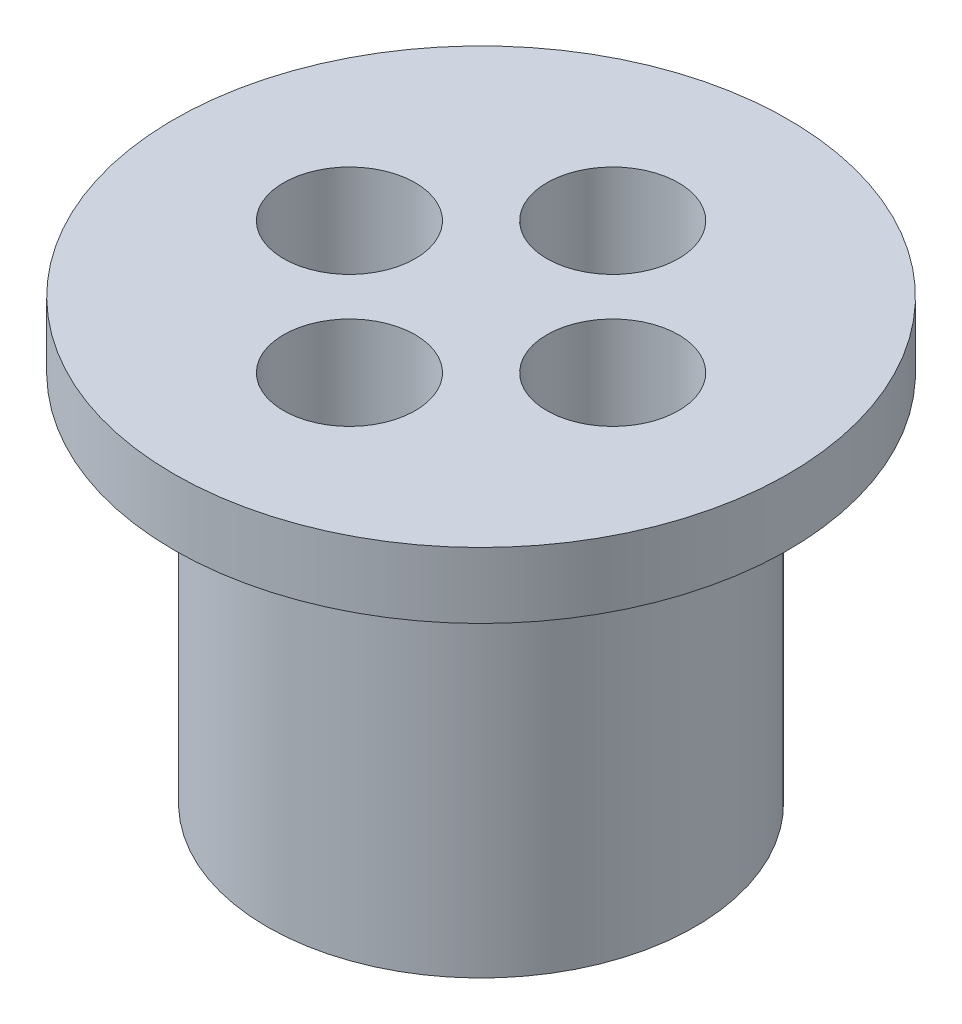
from build123d import *

# Parameters (mm, degrees)
SKETCH1_R           = 9.75
BOSS_EXTRUDE1_DEPTH = 17
SKETCH2_R           = 14
BOSS_EXTRUDE2_DEPTH = 3
SKETCH3_R           = 1.75
CUT_EXTRUDE1_DEPTH  = 21
CIRPATTERN1_COUNT   = 4
SKETCH4_R           = 3
CUT_EXTRUDE2_DEPTH  = 10
CIRPATTERN2_COUNT   = 4


with BuildPart() as part:
    # Sketch1 → Boss-Extrude1 (new body)
    with BuildSketch(Plane(origin=(0, 0, 0), x_dir=(1, 0, 0), z_dir=(0, 1, 0))):
        Circle(SKETCH1_R)
    extrude(amount=BOSS_EXTRUDE1_DEPTH)

    # Sketch2 → Boss-Extrude2 (add)
    with BuildSketch(Plane(origin=(0, 17, 0), x_dir=(1, 0, 0), z_dir=(0, 1, 0))):
        Circle(SKETCH2_R)
    extrude(amount=BOSS_EXTRUDE2_DEPTH)

    # Sketch3 → Cut-Extrude1 (cut, through all)
    with BuildSketch(Plane.XZ):
        with Locations((0, 6)):
            Circle(SKETCH3_R)
    cut_extrude1 = extrude(amount=-CUT_EXTRUDE1_DEPTH, mode=Mode.SUBTRACT)

    # CirPattern1: Cut-Extrude1 ×4 about axis
    cirpattern1_axis = Axis((0, 0, 0), (0, 1, 0))
    for i in range(1, CIRPATTERN1_COUNT):
        add(cut_extrude1.rotate(cirpattern1_axis, i * 360 / CIRPATTERN1_COUNT), mode=Mode.SUBTRACT)

    # Sketch4 → Cut-Extrude2 (cut)
    with BuildSketch(Plane(origin=(0, 20, 0), x_dir=(1, 0, 0), z_dir=(0, 1, 0))):
        with Locations((0, 6)):
            Circle(SKETCH4_R)
    cut_extrude2 = extrude(amount=-CUT_EXTRUDE2_DEPTH, mode=Mode.SUBTRACT)

    # CirPattern2: Cut-Extrude2 ×4 about axis
    cirpattern2_axis = Axis((0, 0, 0), (0, 1, 0))
    for i in range(1, CIRPATTERN2_COUNT):
        add(cut_extrude2.rotate(cirpattern2_axis, i * 360 / CIRPATTERN2_COUNT), mode=Mode.SUBTRACT)


solid = part.part
